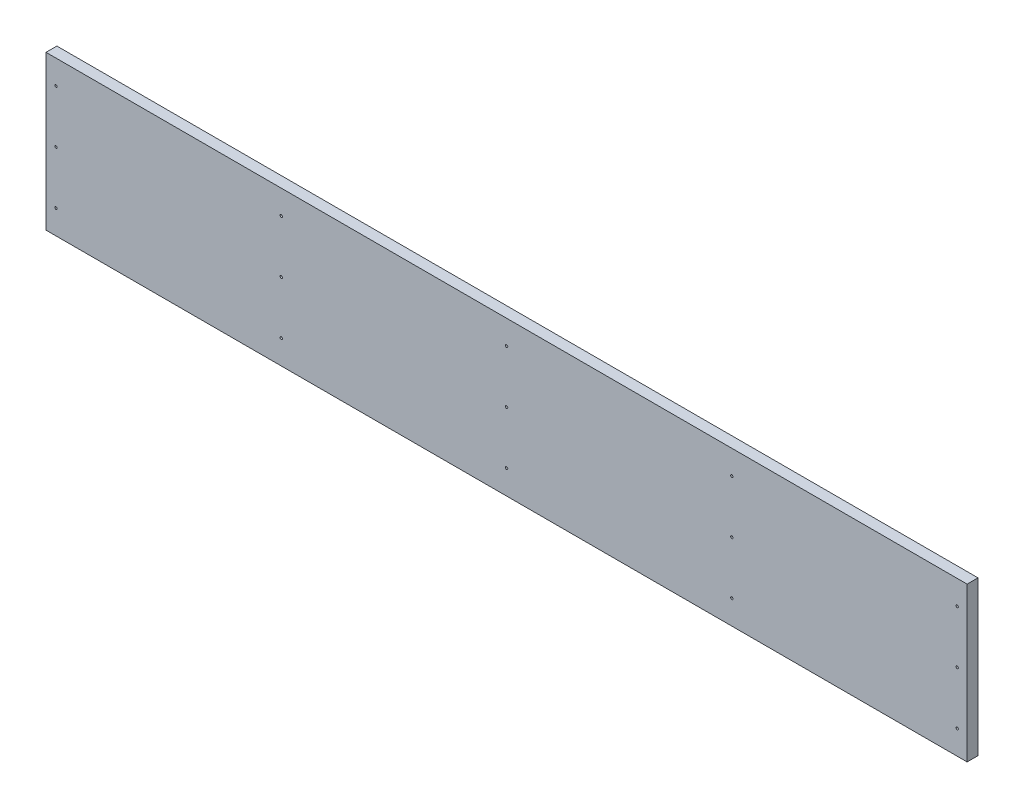
from build123d import *

# Parameters (mm, degrees)
SKIZZE1_W                       = 1525
SKIZZE1_H                       = 255
AUFSATZ_LINEAR_AUSTRAGEN1_DEPTH = 18
SCHNITT_LINEAR_AUSTRAGEN1_REACH = 20
SKIZZE3_R                       = 2


with BuildPart() as part:
    # Skizze1 → Aufsatz-Linear austragen1 (new body)
    with BuildSketch(Plane.XY):
        Rectangle(SKIZZE1_W, SKIZZE1_H)
    extrude(amount=AUFSATZ_LINEAR_AUSTRAGEN1_DEPTH)

    # Skizze3 → Schnitt-Linear austragen1 (cut, up to next)
    with BuildSketch(Plane.XY.offset(18), mode=Mode.PRIVATE) as schnitt_linear_austragen1_sk1:
        with Locations((-746, 87.5)):
            Circle(SKIZZE3_R)
    schnitt_linear_austragen1_tool1 = extrude(schnitt_linear_austragen1_sk1.sketch, amount=-SCHNITT_LINEAR_AUSTRAGEN1_REACH, mode=Mode.PRIVATE) & part.part
    add(schnitt_linear_austragen1_tool1.solids().sort_by_distance((-746, 87.5, 18))[0], mode=Mode.SUBTRACT)
    # Skizze3 → Schnitt-Linear austragen1 (cut, up to next)
    with BuildSketch(Plane.XY.offset(18), mode=Mode.PRIVATE) as schnitt_linear_austragen1_sk2:
        with Locations((-746, 0)):
            Circle(SKIZZE3_R)
    schnitt_linear_austragen1_tool2 = extrude(schnitt_linear_austragen1_sk2.sketch, amount=-SCHNITT_LINEAR_AUSTRAGEN1_REACH, mode=Mode.PRIVATE) & part.part
    add(schnitt_linear_austragen1_tool2.solids().sort_by_distance((-746, 0, 18))[0], mode=Mode.SUBTRACT)
    # Skizze3 → Schnitt-Linear austragen1 (cut, up to next)
    with BuildSketch(Plane.XY.offset(18), mode=Mode.PRIVATE) as schnitt_linear_austragen1_sk3:
        with Locations((-746, -87.5)):
            Circle(SKIZZE3_R)
    schnitt_linear_austragen1_tool3 = extrude(schnitt_linear_austragen1_sk3.sketch, amount=-SCHNITT_LINEAR_AUSTRAGEN1_REACH, mode=Mode.PRIVATE) & part.part
    add(schnitt_linear_austragen1_tool3.solids().sort_by_distance((-746, -87.5, 18))[0], mode=Mode.SUBTRACT)
    # Skizze3 → Schnitt-Linear austragen1 (cut, up to next)
    with BuildSketch(Plane.XY.offset(18), mode=Mode.PRIVATE) as schnitt_linear_austragen1_sk4:
        with Locations((-373, -87.5)):
            Circle(SKIZZE3_R)
    schnitt_linear_austragen1_tool4 = extrude(schnitt_linear_austragen1_sk4.sketch, amount=-SCHNITT_LINEAR_AUSTRAGEN1_REACH, mode=Mode.PRIVATE) & part.part
    add(schnitt_linear_austragen1_tool4.solids().sort_by_distance((-373, -87.5, 18))[0], mode=Mode.SUBTRACT)
    # Skizze3 → Schnitt-Linear austragen1 (cut, up to next)
    with BuildSketch(Plane.XY.offset(18), mode=Mode.PRIVATE) as schnitt_linear_austragen1_sk5:
        with Locations((-373, 0)):
            Circle(SKIZZE3_R)
    schnitt_linear_austragen1_tool5 = extrude(schnitt_linear_austragen1_sk5.sketch, amount=-SCHNITT_LINEAR_AUSTRAGEN1_REACH, mode=Mode.PRIVATE) & part.part
    add(schnitt_linear_austragen1_tool5.solids().sort_by_distance((-373, 0, 18))[0], mode=Mode.SUBTRACT)
    # Skizze3 → Schnitt-Linear austragen1 (cut, up to next)
    with BuildSketch(Plane.XY.offset(18), mode=Mode.PRIVATE) as schnitt_linear_austragen1_sk6:
        with Locations((-373, 87.5)):
            Circle(SKIZZE3_R)
    schnitt_linear_austragen1_tool6 = extrude(schnitt_linear_austragen1_sk6.sketch, amount=-SCHNITT_LINEAR_AUSTRAGEN1_REACH, mode=Mode.PRIVATE) & part.part
    add(schnitt_linear_austragen1_tool6.solids().sort_by_distance((-373, 87.5, 18))[0], mode=Mode.SUBTRACT)
    # Skizze3 → Schnitt-Linear austragen1 (cut, up to next)
    with BuildSketch(Plane.XY.offset(18), mode=Mode.PRIVATE) as schnitt_linear_austragen1_sk7:
        with Locations((0, -87.5)):
            Circle(SKIZZE3_R)
    schnitt_linear_austragen1_tool7 = extrude(schnitt_linear_austragen1_sk7.sketch, amount=-SCHNITT_LINEAR_AUSTRAGEN1_REACH, mode=Mode.PRIVATE) & part.part
    add(schnitt_linear_austragen1_tool7.solids().sort_by_distance((0, -87.5, 18))[0], mode=Mode.SUBTRACT)
    # Skizze3 → Schnitt-Linear austragen1 (cut, up to next)
    with BuildSketch(Plane.XY.offset(18), mode=Mode.PRIVATE) as schnitt_linear_austragen1_sk8:
        Circle(SKIZZE3_R)
    schnitt_linear_austragen1_tool8 = extrude(schnitt_linear_austragen1_sk8.sketch, amount=-SCHNITT_LINEAR_AUSTRAGEN1_REACH, mode=Mode.PRIVATE) & part.part
    add(schnitt_linear_austragen1_tool8.solids().sort_by_distance((0, 0, 18))[0], mode=Mode.SUBTRACT)
    # Skizze3 → Schnitt-Linear austragen1 (cut, up to next)
    with BuildSketch(Plane.XY.offset(18), mode=Mode.PRIVATE) as schnitt_linear_austragen1_sk9:
        with Locations((0, 87.5)):
            Circle(SKIZZE3_R)
    schnitt_linear_austragen1_tool9 = extrude(schnitt_linear_austragen1_sk9.sketch, amount=-SCHNITT_LINEAR_AUSTRAGEN1_REACH, mode=Mode.PRIVATE) & part.part
    add(schnitt_linear_austragen1_tool9.solids().sort_by_distance((0, 87.5, 18))[0], mode=Mode.SUBTRACT)
    # Skizze3 → Schnitt-Linear austragen1 (cut, up to next)
    with BuildSketch(Plane.XY.offset(18), mode=Mode.PRIVATE) as schnitt_linear_austragen1_sk10:
        with Locations((373, -87.5)):
            Circle(SKIZZE3_R)
    schnitt_linear_austragen1_tool10 = extrude(schnitt_linear_austragen1_sk10.sketch, amount=-SCHNITT_LINEAR_AUSTRAGEN1_REACH, mode=Mode.PRIVATE) & part.part
    add(schnitt_linear_austragen1_tool10.solids().sort_by_distance((373, -87.5, 18))[0], mode=Mode.SUBTRACT)
    # Skizze3 → Schnitt-Linear austragen1 (cut, up to next)
    with BuildSketch(Plane.XY.offset(18), mode=Mode.PRIVATE) as schnitt_linear_austragen1_sk11:
        with Locations((373, 0)):
            Circle(SKIZZE3_R)
    schnitt_linear_austragen1_tool11 = extrude(schnitt_linear_austragen1_sk11.sketch, amount=-SCHNITT_LINEAR_AUSTRAGEN1_REACH, mode=Mode.PRIVATE) & part.part
    add(schnitt_linear_austragen1_tool11.solids().sort_by_distance((373, 0, 18))[0], mode=Mode.SUBTRACT)
    # Skizze3 → Schnitt-Linear austragen1 (cut, up to next)
    with BuildSketch(Plane.XY.offset(18), mode=Mode.PRIVATE) as schnitt_linear_austragen1_sk12:
        with Locations((373, 87.5)):
            Circle(SKIZZE3_R)
    schnitt_linear_austragen1_tool12 = extrude(schnitt_linear_austragen1_sk12.sketch, amount=-SCHNITT_LINEAR_AUSTRAGEN1_REACH, mode=Mode.PRIVATE) & part.part
    add(schnitt_linear_austragen1_tool12.solids().sort_by_distance((373, 87.5, 18))[0], mode=Mode.SUBTRACT)
    # Skizze3 → Schnitt-Linear austragen1 (cut, up to next)
    with BuildSketch(Plane.XY.offset(18), mode=Mode.PRIVATE) as schnitt_linear_austragen1_sk13:
        with Locations((746, -87.5)):
            Circle(SKIZZE3_R)
    schnitt_linear_austragen1_tool13 = extrude(schnitt_linear_austragen1_sk13.sketch, amount=-SCHNITT_LINEAR_AUSTRAGEN1_REACH, mode=Mode.PRIVATE) & part.part
    add(schnitt_linear_austragen1_tool13.solids().sort_by_distance((746, -87.5, 18))[0], mode=Mode.SUBTRACT)
    # Skizze3 → Schnitt-Linear austragen1 (cut, up to next)
    with BuildSketch(Plane.XY.offset(18), mode=Mode.PRIVATE) as schnitt_linear_austragen1_sk14:
        with Locations((746, 0)):
            Circle(SKIZZE3_R)
    schnitt_linear_austragen1_tool14 = extrude(schnitt_linear_austragen1_sk14.sketch, amount=-SCHNITT_LINEAR_AUSTRAGEN1_REACH, mode=Mode.PRIVATE) & part.part
    add(schnitt_linear_austragen1_tool14.solids().sort_by_distance((746, 0, 18))[0], mode=Mode.SUBTRACT)
    # Skizze3 → Schnitt-Linear austragen1 (cut, up to next)
    with BuildSketch(Plane.XY.offset(18), mode=Mode.PRIVATE) as schnitt_linear_austragen1_sk15:
        with Locations((746, 87.5)):
            Circle(SKIZZE3_R)
    schnitt_linear_austragen1_tool15 = extrude(schnitt_linear_austragen1_sk15.sketch, amount=-SCHNITT_LINEAR_AUSTRAGEN1_REACH, mode=Mode.PRIVATE) & part.part
    add(schnitt_linear_austragen1_tool15.solids().sort_by_distance((746, 87.5, 18))[0], mode=Mode.SUBTRACT)


solid = part.part
